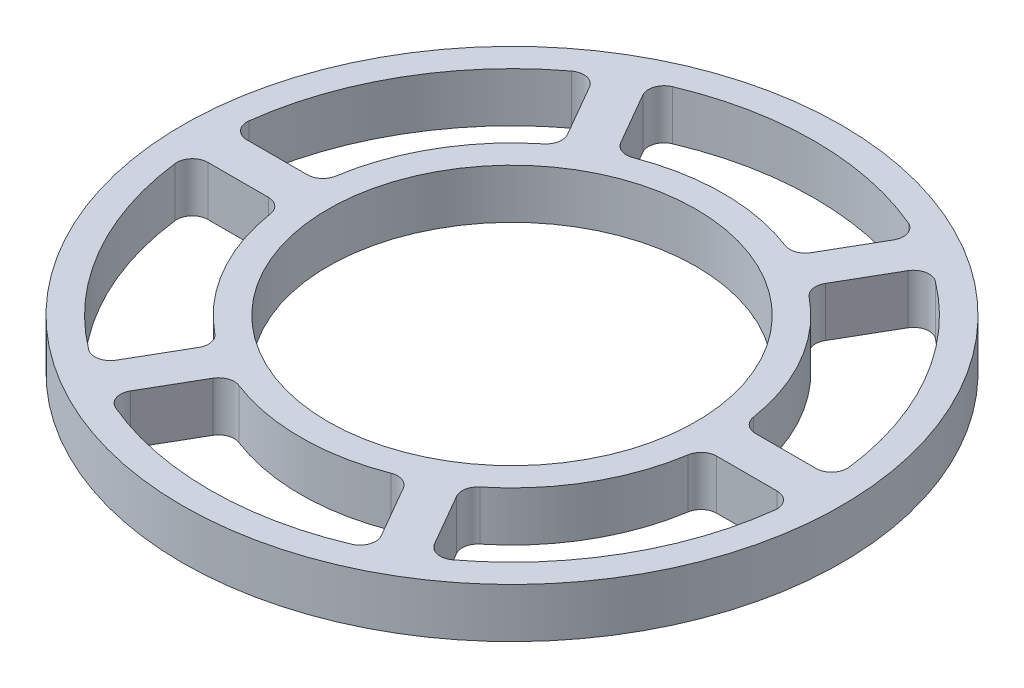
from build123d import *

# Parameters (mm, degrees)
SKETCH2_W                = 33.3375
SKETCH2_H                = 12.7
CUT_EXTRUDE1_DEPTH       = 13.7
FILLET1_R                = 4
CIRPATTERN4_COUNT        = 6
FILLET1_OF_CIRPATTERN4_R = 4
SKETCH9_R                = 49.2125
SKETCH9_R_2              = 47.2125
BOSS_EXTRUDE1_DEPTH      = 12.7
SKETCH10_R               = 84.55
SKETCH10_R_2             = 82.55
BOSS_EXTRUDE2_DEPTH      = 12.7


with BuildPart() as part:
    # Sketch2 → Revolve1 (revolve)
    with BuildSketch(Plane(origin=(0, 0, 0), x_dir=(0, 0, -1), z_dir=(1, 0, 0))):
        with Locations((-65.88125, 6.35)):
            Rectangle(SKETCH2_W, SKETCH2_H)
    revolve(axis=Axis((0, -0.5, 0), (0, 1, 0)))

    # Sketch8 → Cut-Extrude1 (cut, through all)
    with BuildSketch(Plane(origin=(0, 12.7, 0), x_dir=(1, 0, 0), z_dir=(0, 1, 0))):
        with BuildLine():
            Line((-22.66059, 49.249293), (-34.364196, 69.520533))
            ThreePointArc((-34.364196, 69.520533), (0, 77.55), (34.364196, 69.520533))
            Line((34.364196, 69.520533), (22.66059, 49.249293))
            ThreePointArc((22.66059, 49.249293), (0, 54.2125), (-22.66059, 49.249293))
        make_face()
    cut_extrude1 = extrude(amount=-CUT_EXTRUDE1_DEPTH, mode=Mode.SUBTRACT)

    # Fillet1
    fillet1_edges = [part.edges().sort_by_distance(p)[0] for p in [
        (22.66059, 6.35, -49.249293),
        (-22.66059, 6.35, -49.249293),
        (-34.364196, 6.35, -69.520533),
        (34.364196, 6.35, -69.520533),
    ]]
    fillet(fillet1_edges, radius=FILLET1_R)

    # CirPattern4: Cut-Extrude1 ×6 about axis
    cirpattern4_axis = Axis((0, 0, 0), (0, 1, 0))
    for i in range(1, CIRPATTERN4_COUNT):
        add(cut_extrude1.rotate(cirpattern4_axis, i * 360 / CIRPATTERN4_COUNT), mode=Mode.SUBTRACT)

    # Fillet1 of CirPattern4
    fillet1_of_cirpattern4_edges = [part.edges().sort_by_distance(p)[0] for p in [
        (-31.320844, 6.35, -44.249293),
        (-53.981433, 6.35, -5),
        (-77.388646, 6.35, -5),
        (-43.02445, 6.35, -64.520533),
        (-53.981433, 6.35, 5),
        (-31.320844, 6.35, 44.249293),
        (-43.02445, 6.35, 64.520533),
        (-77.388646, 6.35, 5),
        (-22.66059, 6.35, 49.249293),
        (22.66059, 6.35, 49.249293),
        (34.364196, 6.35, 69.520533),
        (-34.364196, 6.35, 69.520533),
        (31.320844, 6.35, 44.249293),
        (53.981433, 6.35, 5),
        (77.388646, 6.35, 5),
        (43.02445, 6.35, 64.520533),
        (53.981433, 6.35, -5),
        (31.320844, 6.35, -44.249293),
        (43.02445, 6.35, -64.520533),
        (77.388646, 6.35, -5),
    ]]
    fillet(fillet1_of_cirpattern4_edges, radius=FILLET1_OF_CIRPATTERN4_R)

    # Sketch9 → Boss-Extrude1 (add)
    with BuildSketch(Plane(origin=(0, 0, 0), x_dir=(1, 0, 0), z_dir=(0, 1, 0))):
        Circle(SKETCH9_R)
        Circle(SKETCH9_R_2, mode=Mode.SUBTRACT)
    extrude(amount=BOSS_EXTRUDE1_DEPTH)

    # Sketch10 → Boss-Extrude2 (add)
    with BuildSketch(Plane(origin=(0, 0, 0), x_dir=(1, 0, 0), z_dir=(0, 1, 0))):
        Circle(SKETCH10_R)
        Circle(SKETCH10_R_2, mode=Mode.SUBTRACT)
    extrude(amount=BOSS_EXTRUDE2_DEPTH)


solid = part.part
